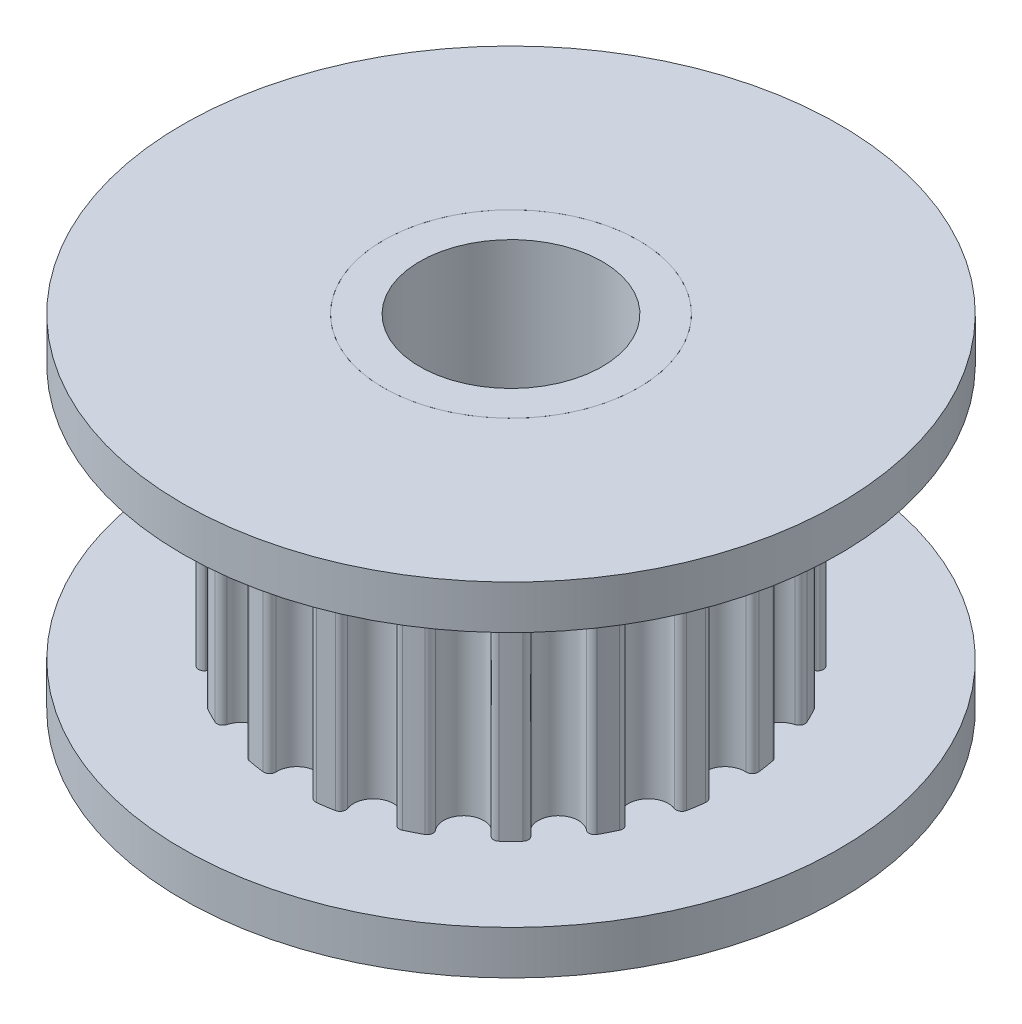
from build123d import *

# Parameters (mm, degrees)
SKICA3_R                 = 9
SKICA3_R_2               = 3.5
P_IDAT_VYSUNUT_M1_DEPTH  = 1.2
SKICA5_R                 = 7.5
ODEBRAT_VYSUNUT_M1_DEPTH = 7
SKICA6_R                 = 9
SKICA6_R_2               = 3.5
P_IDAT_VYSUNUT_M3_DEPTH  = 1.2


with BuildPart() as part:
    # Skica2 → Rotovat1 (revolve)
    with BuildSketch(Plane.XY):
        Polygon((3.5, 9.4), (2.5, 9.4), (2.5, 0), (3.5, 0), (3.5, 1.2), (7.5, 1.2), (7.5, 8.2), (3.5, 8.2), align=None)
    revolve(axis=Axis((0, 0, 0), (0, 1, 0)))

    # Skica5 → Odebrat vysunutím1 (cut)
    with BuildSketch(Plane.XZ.offset(-1.2)):
        Circle(SKICA5_R)
        with BuildLine():
            ThreePointArc((-0.549227949, 5.899131775), (0, 5.32), (0.549227949, 5.899131775))
            ThreePointArc((0.549227949, 5.899131775), (0.599687134, 6.024439536), (0.728068988, 6.06646648))
            ThreePointArc((0.728068988, 6.06646648), (0.955814581, 6.034775761), (1.182206482, 5.994538167))
            ThreePointArc((1.182206482, 5.994538167), (1.291317841, 5.914895994), (1.300585151, 5.780128485))
            ThreePointArc((1.300585151, 5.780128485), (1.64397041, 5.059620667), (2.34527879, 5.440686945))
            ThreePointArc((2.34527879, 5.440686945), (2.431990555, 5.544268962), (2.567075994, 5.544566786))
            ThreePointArc((2.567075994, 5.544566786), (2.773881953, 5.444049863), (2.976759346, 5.335822692))
            ThreePointArc((2.976759346, 5.335822692), (3.05591963, 5.22636122), (3.023087915, 5.095325947))
            ThreePointArc((3.023087915, 5.095325947), (3.127017542, 4.30397041), (3.911757403, 4.44966977))
            ThreePointArc((3.911757403, 4.44966977), (4.026233796, 4.521386713), (4.154799715, 4.479926264))
            ThreePointArc((4.154799715, 4.479926264), (4.320422433, 4.320422433), (4.479926264, 4.154799715))
            ThreePointArc((4.479926264, 4.154799715), (4.521386713, 4.026233796), (4.44966977, 3.911757403))
            ThreePointArc((4.44966977, 3.911757403), (4.30397041, 3.127017542), (5.095325947, 3.023087915))
            ThreePointArc((5.095325947, 3.023087915), (5.22636122, 3.05591963), (5.335822692, 2.976759346))
            ThreePointArc((5.335822692, 2.976759346), (5.444049863, 2.773881953), (5.544566786, 2.567075994))
            ThreePointArc((5.544566786, 2.567075994), (5.544268962, 2.431990555), (5.440686945, 2.34527879))
            ThreePointArc((5.440686945, 2.34527879), (5.059620667, 1.64397041), (5.780128485, 1.300585151))
            ThreePointArc((5.780128485, 1.300585151), (5.914895994, 1.291317841), (5.994538167, 1.182206482))
            ThreePointArc((5.994538167, 1.182206482), (6.034775761, 0.955814581), (6.06646648, 0.728068988))
            ThreePointArc((6.06646648, 0.728068988), (6.024439536, 0.599687134), (5.899131775, 0.549227949))
            ThreePointArc((5.899131775, 0.549227949), (5.32, 0), (5.899131775, -0.549227949))
            ThreePointArc((5.899131775, -0.549227949), (6.024439536, -0.599687134), (6.06646648, -0.728068988))
            ThreePointArc((6.06646648, -0.728068988), (6.034775761, -0.955814581), (5.994538167, -1.182206482))
            ThreePointArc((5.994538167, -1.182206482), (5.914895994, -1.291317841), (5.780128485, -1.300585151))
            ThreePointArc((5.780128485, -1.300585151), (5.059620667, -1.64397041), (5.440686945, -2.34527879))
            ThreePointArc((5.440686945, -2.34527879), (5.544268962, -2.431990555), (5.544566786, -2.567075994))
            ThreePointArc((5.544566786, -2.567075994), (5.444049863, -2.773881953), (5.335822692, -2.976759346))
            ThreePointArc((5.335822692, -2.976759346), (5.22636122, -3.05591963), (5.095325947, -3.023087915))
            ThreePointArc((5.095325947, -3.023087915), (4.30397041, -3.127017542), (4.44966977, -3.911757403))
            ThreePointArc((4.44966977, -3.911757403), (4.521386713, -4.026233796), (4.479926264, -4.154799715))
            ThreePointArc((4.479926264, -4.154799715), (4.320422433, -4.320422433), (4.154799715, -4.479926264))
            ThreePointArc((4.154799715, -4.479926264), (4.026233796, -4.521386713), (3.911757403, -4.44966977))
            ThreePointArc((3.911757403, -4.44966977), (3.127017542, -4.30397041), (3.023087915, -5.095325947))
            ThreePointArc((3.023087915, -5.095325947), (3.05591963, -5.22636122), (2.976759346, -5.335822692))
            ThreePointArc((2.976759346, -5.335822692), (2.773881953, -5.444049863), (2.567075994, -5.544566786))
            ThreePointArc((2.567075994, -5.544566786), (2.431990555, -5.544268962), (2.34527879, -5.440686945))
            ThreePointArc((2.34527879, -5.440686945), (1.64397041, -5.059620667), (1.300585151, -5.780128485))
            ThreePointArc((1.300585151, -5.780128485), (1.291317841, -5.914895994), (1.182206482, -5.994538167))
            ThreePointArc((1.182206482, -5.994538167), (0.955814581, -6.034775761), (0.728068988, -6.06646648))
            ThreePointArc((0.728068988, -6.06646648), (0.599687134, -6.024439536), (0.549227949, -5.899131775))
            ThreePointArc((0.549227949, -5.899131775), (0, -5.32), (-0.549227949, -5.899131775))
            ThreePointArc((-0.549227949, -5.899131775), (-0.599687134, -6.024439536), (-0.728068988, -6.06646648))
            ThreePointArc((-0.728068988, -6.06646648), (-0.955814581, -6.034775761), (-1.182206482, -5.994538167))
            ThreePointArc((-1.182206482, -5.994538167), (-1.291317841, -5.914895994), (-1.300585151, -5.780128485))
            ThreePointArc((-1.300585151, -5.780128485), (-1.64397041, -5.059620667), (-2.34527879, -5.440686945))
            ThreePointArc((-2.34527879, -5.440686945), (-2.431990555, -5.544268962), (-2.567075994, -5.544566786))
            ThreePointArc((-2.567075994, -5.544566786), (-2.773881953, -5.444049863), (-2.976759346, -5.335822692))
            ThreePointArc((-2.976759346, -5.335822692), (-3.05591963, -5.22636122), (-3.023087915, -5.095325947))
            ThreePointArc((-3.023087915, -5.095325947), (-3.127017542, -4.30397041), (-3.911757403, -4.44966977))
            ThreePointArc((-3.911757403, -4.44966977), (-4.026233796, -4.521386713), (-4.154799715, -4.479926264))
            ThreePointArc((-4.154799715, -4.479926264), (-4.320422433, -4.320422433), (-4.479926264, -4.154799715))
            ThreePointArc((-4.479926264, -4.154799715), (-4.521386713, -4.026233796), (-4.44966977, -3.911757403))
            ThreePointArc((-4.44966977, -3.911757403), (-4.30397041, -3.127017542), (-5.095325947, -3.023087915))
            ThreePointArc((-5.095325947, -3.023087915), (-5.22636122, -3.05591963), (-5.335822692, -2.976759346))
            ThreePointArc((-5.335822692, -2.976759346), (-5.444049863, -2.773881953), (-5.544566786, -2.567075994))
            ThreePointArc((-5.544566786, -2.567075994), (-5.544268962, -2.431990555), (-5.440686945, -2.34527879))
            ThreePointArc((-5.440686945, -2.34527879), (-5.059620667, -1.64397041), (-5.780128485, -1.300585151))
            ThreePointArc((-5.780128485, -1.300585151), (-5.914895994, -1.291317841), (-5.994538167, -1.182206482))
            ThreePointArc((-5.994538167, -1.182206482), (-6.034775761, -0.955814581), (-6.06646648, -0.728068988))
            ThreePointArc((-6.06646648, -0.728068988), (-6.024439536, -0.599687134), (-5.899131775, -0.549227949))
            ThreePointArc((-5.899131775, -0.549227949), (-5.32, 0), (-5.899131775, 0.549227949))
            ThreePointArc((-5.899131775, 0.549227949), (-6.024439536, 0.599687134), (-6.06646648, 0.728068988))
            ThreePointArc((-6.06646648, 0.728068988), (-6.034775761, 0.955814581), (-5.994538167, 1.182206482))
            ThreePointArc((-5.994538167, 1.182206482), (-5.914895994, 1.291317841), (-5.780128485, 1.300585151))
            ThreePointArc((-5.780128485, 1.300585151), (-5.059620667, 1.64397041), (-5.440686945, 2.34527879))
            ThreePointArc((-5.440686945, 2.34527879), (-5.544268962, 2.431990555), (-5.544566786, 2.567075994))
            ThreePointArc((-5.544566786, 2.567075994), (-5.444049863, 2.773881953), (-5.335822692, 2.976759346))
            ThreePointArc((-5.335822692, 2.976759346), (-5.22636122, 3.05591963), (-5.095325947, 3.023087915))
            ThreePointArc((-5.095325947, 3.023087915), (-4.30397041, 3.127017542), (-4.44966977, 3.911757403))
            ThreePointArc((-4.44966977, 3.911757403), (-4.521386713, 4.026233796), (-4.479926264, 4.154799715))
            ThreePointArc((-4.479926264, 4.154799715), (-4.320422433, 4.320422433), (-4.154799715, 4.479926264))
            ThreePointArc((-4.154799715, 4.479926264), (-4.026233796, 4.521386713), (-3.911757403, 4.44966977))
            ThreePointArc((-3.911757403, 4.44966977), (-3.127017542, 4.30397041), (-3.023087915, 5.095325947))
            ThreePointArc((-3.023087915, 5.095325947), (-3.05591963, 5.22636122), (-2.976759346, 5.335822692))
            ThreePointArc((-2.976759346, 5.335822692), (-2.773881953, 5.444049863), (-2.567075994, 5.544566786))
            ThreePointArc((-2.567075994, 5.544566786), (-2.431990555, 5.544268962), (-2.34527879, 5.440686945))
            ThreePointArc((-2.34527879, 5.440686945), (-1.64397041, 5.059620667), (-1.300585151, 5.780128485))
            ThreePointArc((-1.300585151, 5.780128485), (-1.291317841, 5.914895994), (-1.182206482, 5.994538167))
            ThreePointArc((-1.182206482, 5.994538167), (-0.955814581, 6.034775761), (-0.728068988, 6.06646648))
            ThreePointArc((-0.728068988, 6.06646648), (-0.599687134, 6.024439536), (-0.549227949, 5.899131775))
        make_face(mode=Mode.SUBTRACT)
    extrude(amount=-ODEBRAT_VYSUNUT_M1_DEPTH, mode=Mode.SUBTRACT)


with BuildPart() as body_2:
    # Skica3 → Přidat vysunutím1 (new body)
    with BuildSketch(Plane(origin=(0, 9.4, 0), x_dir=(1, 0, 0), z_dir=(0, 1, 0))):
        Circle(SKICA3_R)
        Circle(SKICA3_R_2, mode=Mode.SUBTRACT)
    extrude(amount=-P_IDAT_VYSUNUT_M1_DEPTH)


with BuildPart() as body_3:
    # Skica6 → Přidat vysunutím3 (new body)
    with BuildSketch(Plane.XZ.offset(-1.2)):
        Circle(SKICA6_R)
        Circle(SKICA6_R_2, mode=Mode.SUBTRACT)
    extrude(amount=P_IDAT_VYSUNUT_M3_DEPTH)


solid = Compound([part.part, body_2.part, body_3.part])
